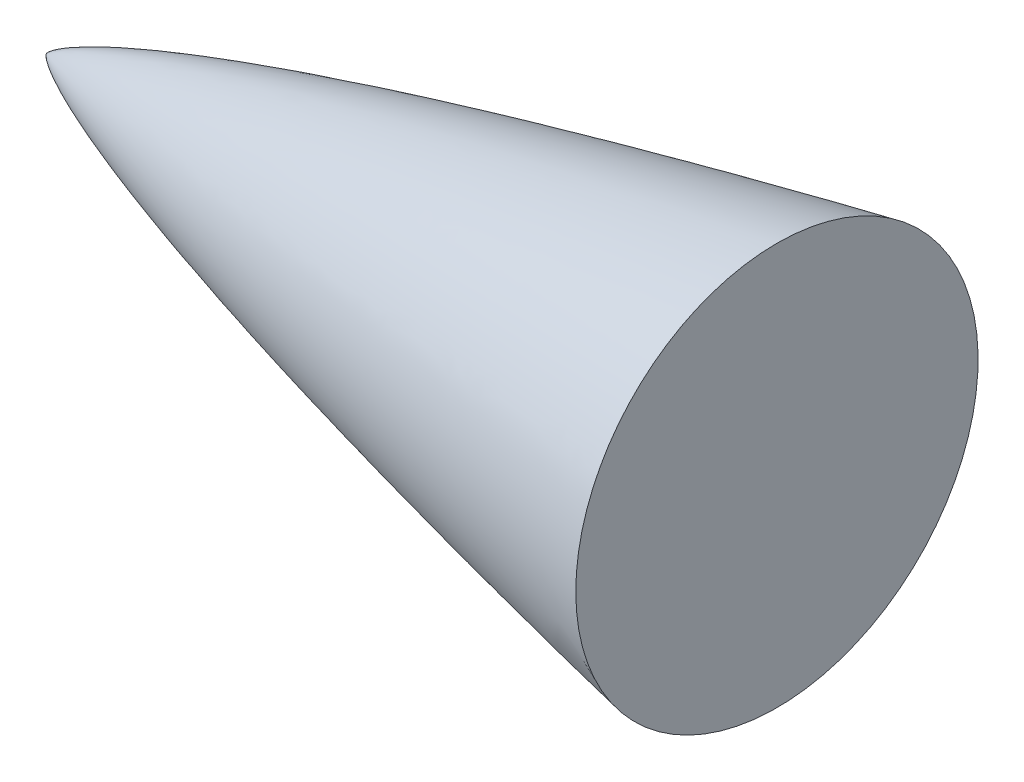
from build123d import *


with BuildPart() as part:
    # Sketch1 → Revolve1 (revolve)
    with BuildSketch(Plane.XY):
        with BuildLine():
            Line((0, 0), (44.45, 0))
            Line((44.45, 0), (44.45, 12.240378041))
            add(Edge.make_bspline(
                [(0, 0), (0.003011993, 0.009762905), (0.010551133, 0.02627483), (0.02586653, 0.047678002), (0.049584294, 0.077338244), (0.081109462, 0.111493124), (0.128401712, 0.157512982), (0.205163795, 0.22377356), (0.332159509, 0.321448772), (0.544576149, 0.465759826), (0.901635526, 0.680174208), (1.511388987, 1.001718774), (2.462796137, 1.442793313), (4.09295059, 2.111247407), (6.381601098, 2.935896342), (9.2264135, 3.855300667), (12.493682634, 4.822076041), (15.835168377, 5.74326247), (19.15770136, 6.611100284), (22.540430849, 7.451044456), (25.848575151, 8.242583042), (29.298149728, 9.033648457), (32.531227192, 9.756334274), (36.13463826, 10.530595732), (39.137485197, 11.164854423), (42.141706029, 11.776943106), (43.678800664, 12.086444553), (44.45, 12.240378041)],
                knots=[0, 0, 0, 0, 0, 0.000801269, 0.001433793, 0.002050484, 0.002997487, 0.004453093, 0.006630366, 0.010023953, 0.015611291, 0.024645739, 0.039425352, 0.064225022, 0.098209944, 0.163173804, 0.23114372, 0.299113647, 0.36708357, 0.435053499, 0.503023422, 0.570993349, 0.638963275, 0.7069332, 0.774903126, 0.842873051, 0.910842976, 0.910842976, 0.910842976, 0.910842976, 0.910842976], degree=4))
        make_face()
    revolve(axis=Axis((0, 0, 0), (1, 0, 0)))


solid = part.part
